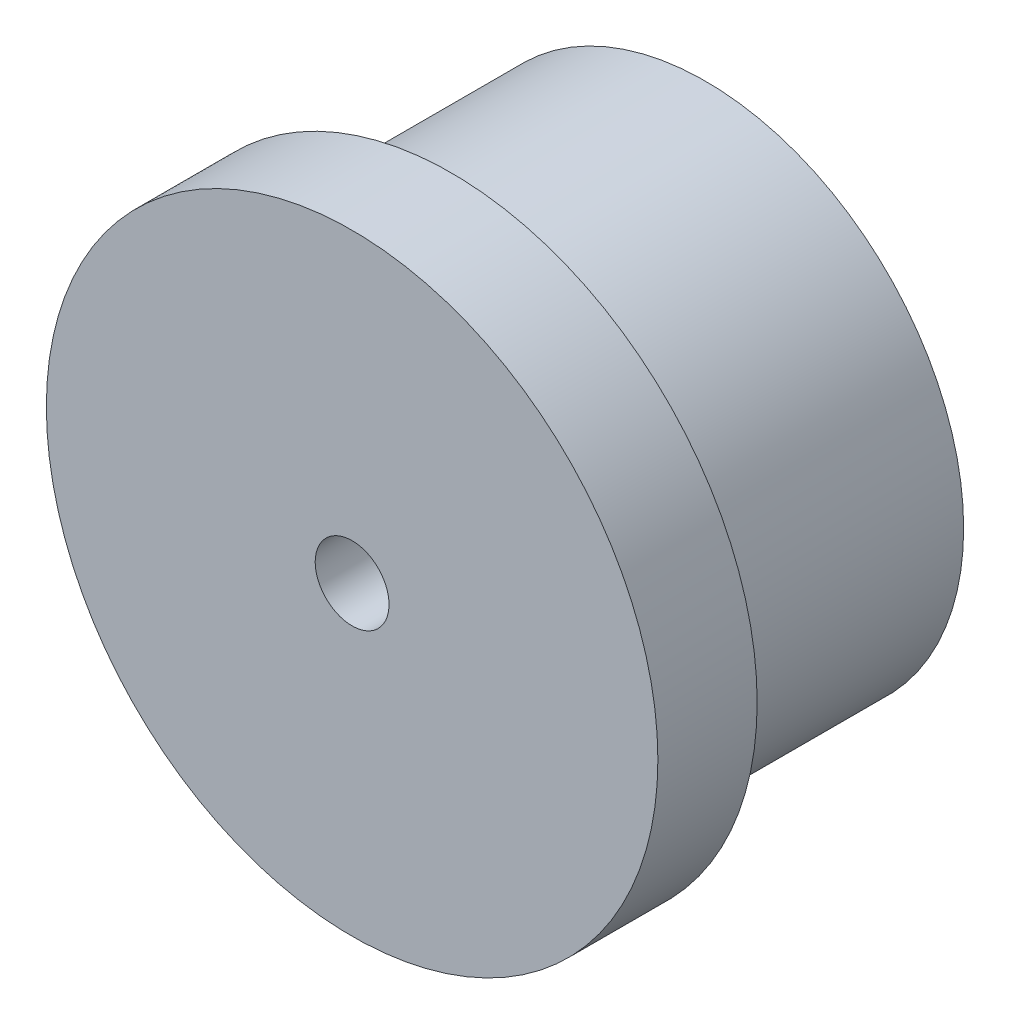
from build123d import *

# Parameters (mm, degrees)
SKETCH1_R                    = 4.1275
BOSS_EXTRUDE2_DEPTH          = 4.064
SKETCH2_R                    = 4.8895
BOSS_EXTRUDE3_DEPTH          = 1.5875
F_56_0_0465_DIAMETER_HOLE1_D = 1.1811


with BuildPart() as part:
    # Sketch1 → Boss-Extrude2 (new body)
    with BuildSketch(Plane.XY):
        with Locations((6.731, -165.7192297)):
            Circle(SKETCH1_R)
    extrude(amount=-BOSS_EXTRUDE2_DEPTH)

    # Sketch2 → Boss-Extrude3 (add)
    with BuildSketch(Plane.XY):
        with Locations((6.731, -165.7192297)):
            Circle(SKETCH2_R)
    extrude(amount=BOSS_EXTRUDE3_DEPTH)

    # #56 (0.0465) Diameter Hole1 (through all)
    with Locations(Plane(origin=(0, 0, -4.064), x_dir=(-1, 0, 0), z_dir=(0, 0, -1))):
        with Locations((-6.731, -165.7192297)):
            Hole(F_56_0_0465_DIAMETER_HOLE1_D / 2)


solid = part.part
